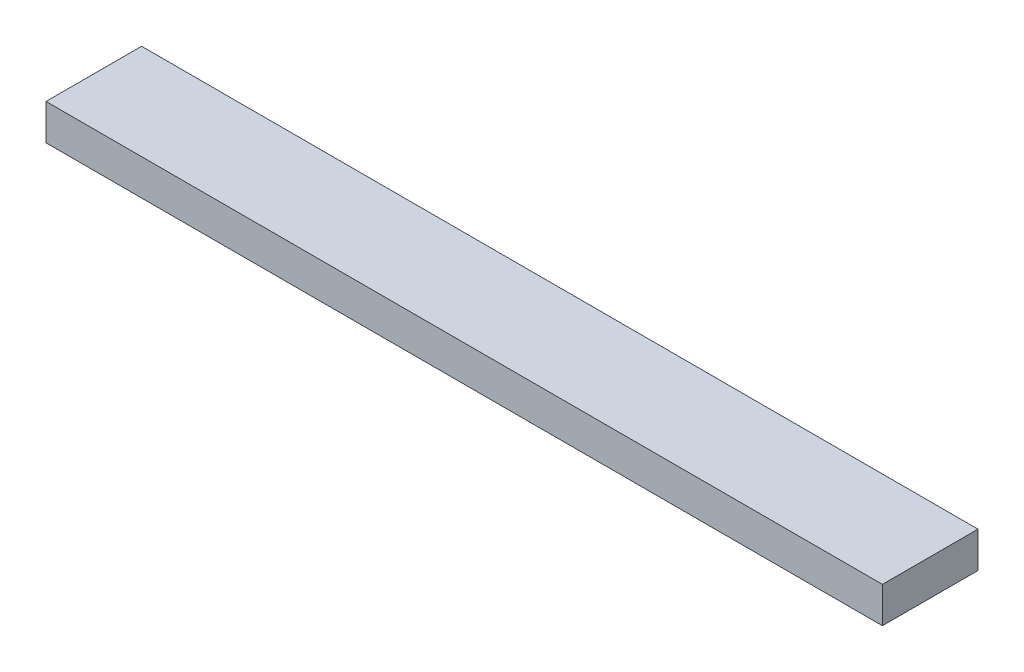
from build123d import *

# Parameters (mm, degrees)
IZIM1_W                     = 700
IZIM1_H                     = 80
Y_KSEKLIK_EKSTR_ZYON1_DEPTH = 30


with BuildPart() as part:
    # Çizim1 → Yükseklik-Ekstrüzyon1 (new body)
    with BuildSketch(Plane(origin=(0, 0, 0), x_dir=(1, 0, 0), z_dir=(0, 1, 0))):
        Rectangle(IZIM1_W, IZIM1_H)
    extrude(amount=-Y_KSEKLIK_EKSTR_ZYON1_DEPTH)


solid = part.part
